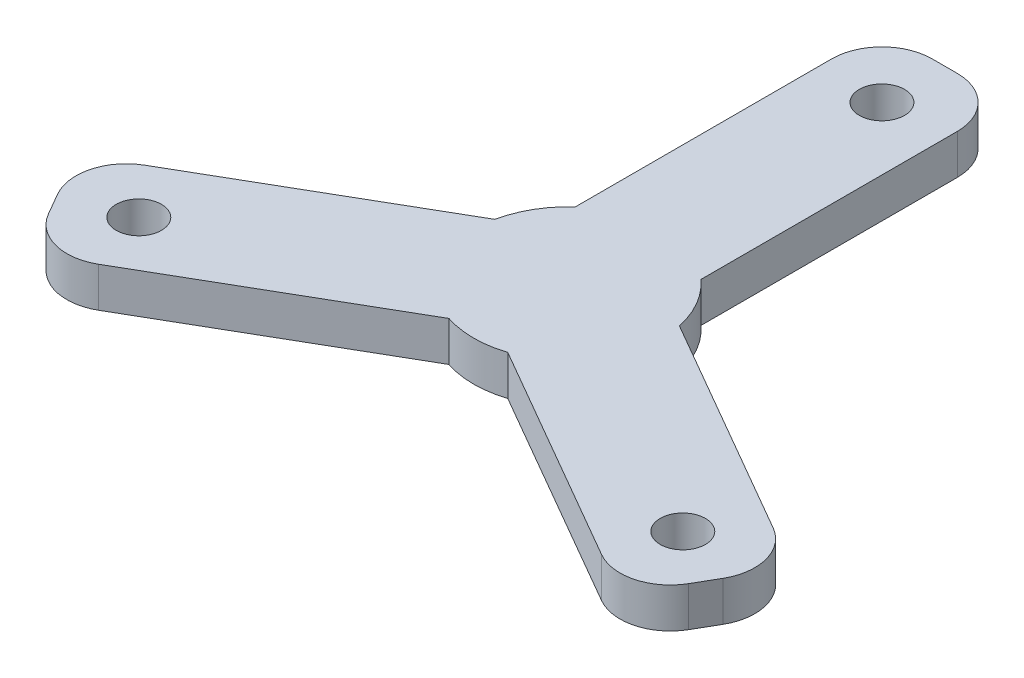
from build123d import *

# Parameters (mm, degrees)
SKETCH1_R           = 7.5
SKETCH1_R_2         = 5
SKETCH1_R_3         = 1.8
BOSS_EXTRUDE1_DEPTH = 3.175


with BuildPart() as part:
    # Sketch1 → Boss-Extrude1 (new body)
    with BuildSketch(Plane(origin=(0, 0, 0), x_dir=(1, 0, 0), z_dir=(0, 1, 0))):
        Circle(SKETCH1_R)
        Circle(SKETCH1_R_2, mode=Mode.SUBTRACT)
        with BuildLine():
            Line((2.5, 4.330127019), (-2.5, -4.330127019))
            Line((-2.5, -4.330127019), (20.016660498, -17.330127019))
            ThreePointArc((20.016660498, -17.330127019), (23.051936679, -17.729728709), (25.480762114, -15.866025404))
            Line((25.480762114, -15.866025404), (26.480762114, -14.133974596))
            ThreePointArc((26.480762114, -14.133974596), (26.880363804, -11.098698416), (25.016660498, -8.669872981))
            Line((25.016660498, -8.669872981), (2.5, 4.330127019))
        make_face()
        with Locations((21.650635095, -12.5)):
            Circle(SKETCH1_R_3, mode=Mode.SUBTRACT)
        with BuildLine():
            Line((-5, 0), (5, 0))
            Line((5, 0), (5, 26))
            ThreePointArc((5, 26), (3.828427125, 28.828427125), (1, 30))
            Line((1, 30), (-1, 30))
            ThreePointArc((-1, 30), (-3.828427125, 28.828427125), (-5, 26))
            Line((-5, 26), (-5, 0))
        make_face()
        with Locations((0, 25)):
            Circle(SKETCH1_R_3, mode=Mode.SUBTRACT)
        with BuildLine():
            Line((2.5, -4.330127019), (-2.5, 4.330127019))
            Line((-2.5, 4.330127019), (-25.016660498, -8.669872981))
            ThreePointArc((-25.016660498, -8.669872981), (-26.880363804, -11.098698416), (-26.480762114, -14.133974596))
            Line((-26.480762114, -14.133974596), (-25.480762114, -15.866025404))
            ThreePointArc((-25.480762114, -15.866025404), (-23.051936679, -17.729728709), (-20.016660498, -17.330127019))
            Line((-20.016660498, -17.330127019), (2.5, -4.330127019))
        make_face()
        with Locations((-21.650635095, -12.5)):
            Circle(SKETCH1_R_3, mode=Mode.SUBTRACT)
    extrude(amount=BOSS_EXTRUDE1_DEPTH)


solid = part.part
